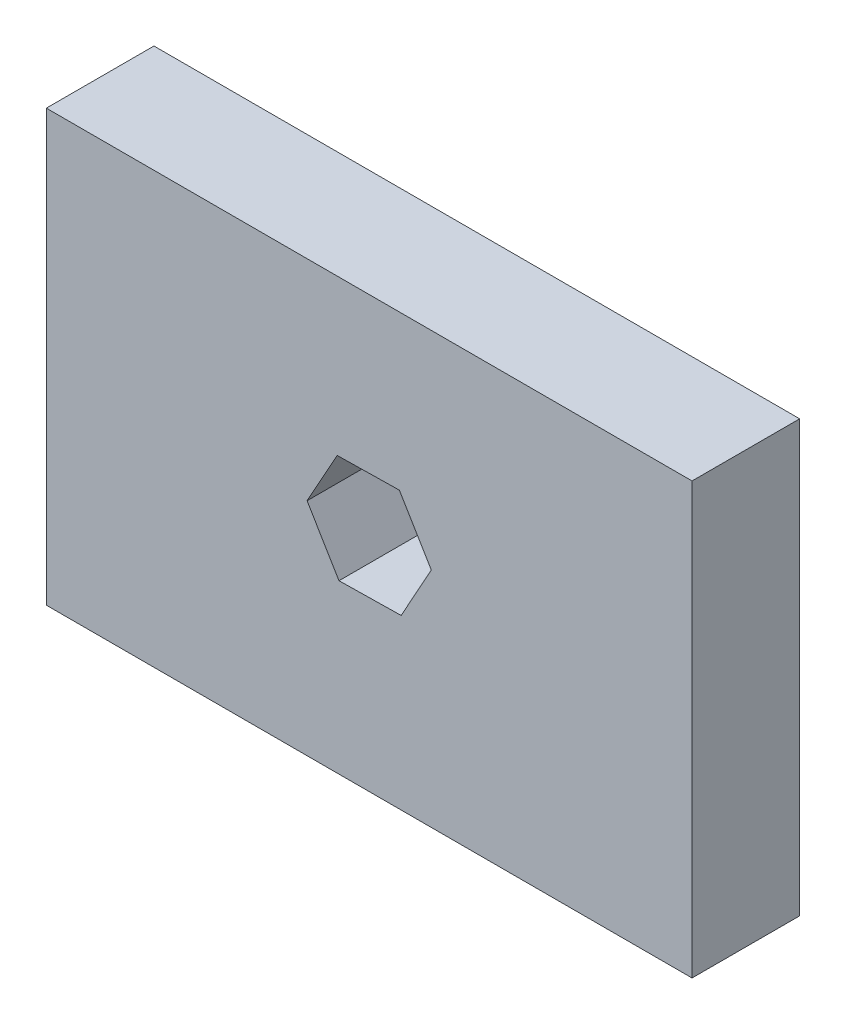
from build123d import *

# Parameters (mm, degrees)
SKETCH1_W           = 76.2
SKETCH1_H           = 50.8
BOSS_EXTRUDE1_DEPTH = 6.35
CUT_EXTRUDE1_DEPTH  = 13.7


with BuildPart() as part:
    # Sketch1 → Boss-Extrude1 (new body, symmetric)
    with BuildSketch(Plane.XY):
        Rectangle(SKETCH1_W, SKETCH1_H)
    extrude(amount=BOSS_EXTRUDE1_DEPTH, both=True)

    # Sketch3 → Cut-Extrude1 (cut, through all)
    with BuildSketch(Plane.XY.offset(6.35)):
        Polygon((-3.5620661, -5.630417032), (3.769306023, -5.510767006), (7.331372123, 0.89821251), (3.5620661, 7.187542), (-3.769306023, 7.067891975), (-7.331372123, 0.658912459), align=None)
    extrude(amount=-CUT_EXTRUDE1_DEPTH, mode=Mode.SUBTRACT)


solid = part.part
